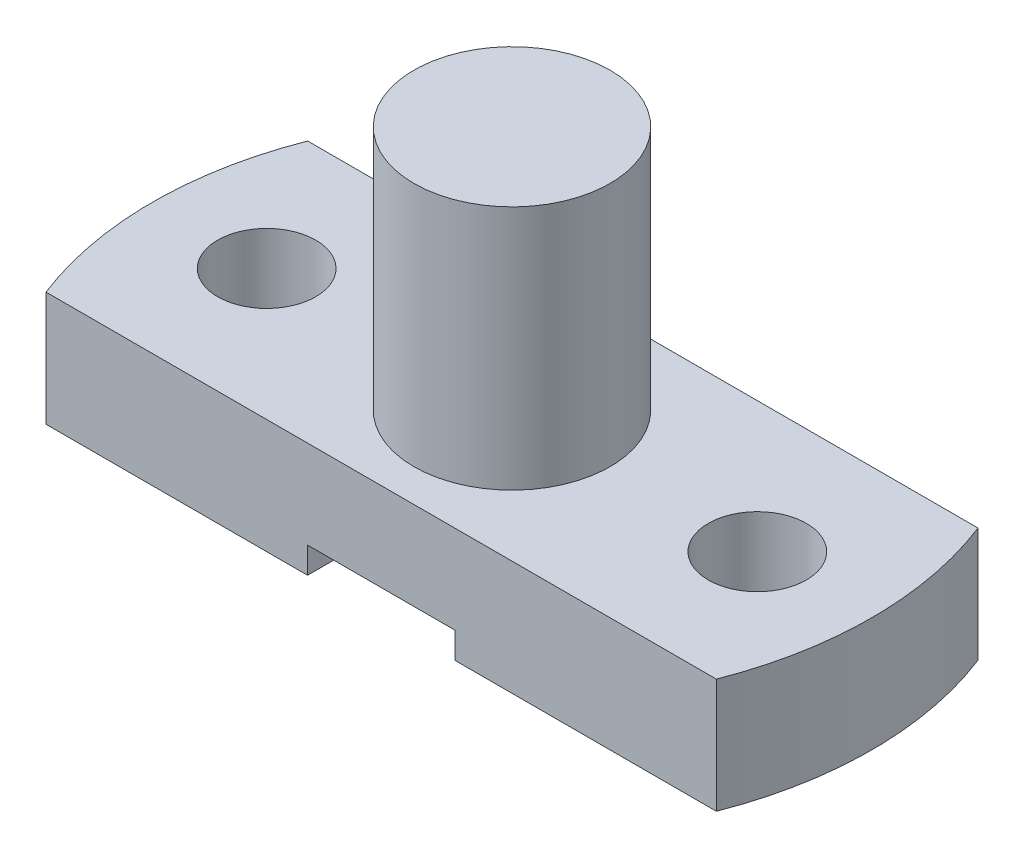
from build123d import *

# Parameters (mm, degrees)
SKETCH1_R           = 15
BOSS_EXTRUDE2_DEPTH = 35
SKETCH2_R           = 30
BOSS_EXTRUDE3_DEPTH = 75
SKETCH3_W           = 45
SKETCH3_H           = 80
CUT_EXTRUDE1_DEPTH  = 8


with BuildPart() as part:
    # Sketch1 → Boss-Extrude2 (new body)
    with BuildSketch(Plane(origin=(0, 0, 0), x_dir=(1, 0, 0), z_dir=(0, 1, 0))):
        with BuildLine():
            Line((-102.46950766, 40), (102.46950766, 40))
            ThreePointArc((102.46950766, 40), (110, 0), (102.46950766, -40))
            Line((102.46950766, -40), (-102.46950766, -40))
            ThreePointArc((-102.46950766, -40), (-110, 0), (-102.46950766, 40))
        make_face()
        with Locations((75, 0)):
            Circle(SKETCH1_R, mode=Mode.SUBTRACT)
        with Locations((-75, 0)):
            Circle(SKETCH1_R, mode=Mode.SUBTRACT)
    extrude(amount=BOSS_EXTRUDE2_DEPTH)

    # Sketch2 → Boss-Extrude3 (add)
    with BuildSketch(Plane(origin=(0, 35, 0), x_dir=(1, 0, 0), z_dir=(0, 1, 0))):
        Circle(SKETCH2_R)
    extrude(amount=BOSS_EXTRUDE3_DEPTH)

    # Sketch3 → Cut-Extrude1 (cut)
    with BuildSketch(Plane.XZ):
        Rectangle(SKETCH3_W, SKETCH3_H)
    extrude(amount=-CUT_EXTRUDE1_DEPTH, mode=Mode.SUBTRACT)


solid = part.part
